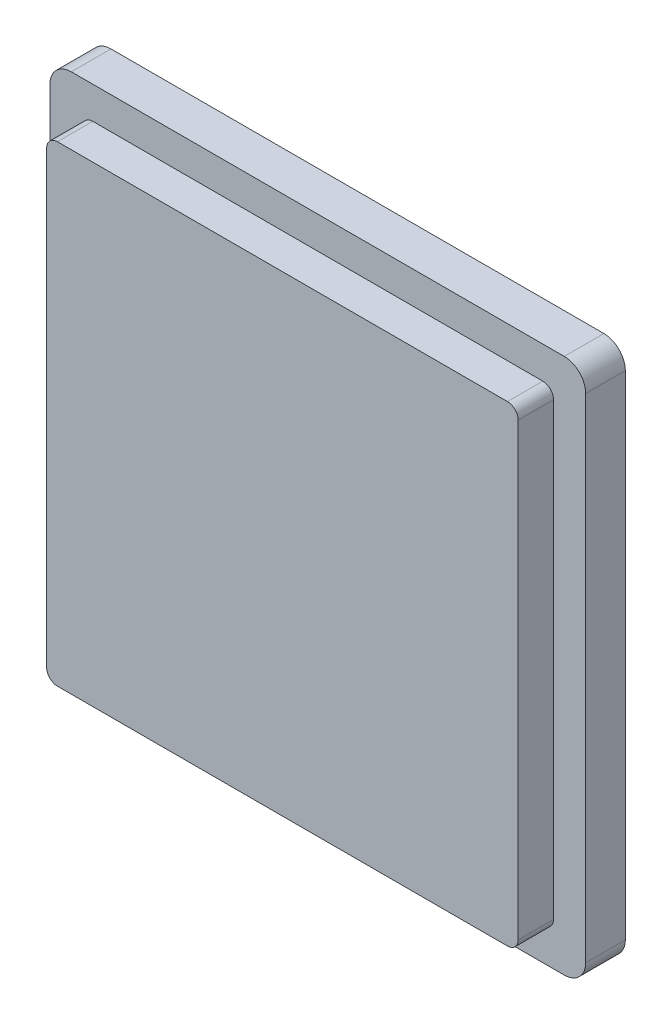
from build123d import *

# Parameters (mm, degrees)
RESSALTO_EXTRUS_O1_DEPTH = 3.7
RESSALTO_EXTRUS_O2_DEPTH = 3.3


with BuildPart() as part:
    # Esboço1 → Ressalto-extrusão1 (new body)
    with BuildSketch(Plane.XY):
        with BuildLine():
            Line((23, -25), (-23, -25))
            ThreePointArc((-23, -25), (-24.414213563, -24.414213562), (-25, -23))
            Line((-25, -23), (-25, 23))
            ThreePointArc((-25, 23), (-24.414213563, 24.414213562), (-23, 25))
            Line((-23, 25), (23, 25))
            ThreePointArc((23, 25), (24.414213563, 24.414213562), (25, 23))
            Line((25, 23), (25, -23))
            ThreePointArc((25, -23), (24.414213563, -24.414213562), (23, -25))
        make_face()
    extrude(amount=RESSALTO_EXTRUS_O1_DEPTH)

    # Esboço3 → Ressalto-extrusão2 (add)
    with BuildSketch(Plane.XY.offset(3.7)):
        with BuildLine():
            Line((-22, -21), (-22, 21))
            ThreePointArc((-22, 21), (-21.707106782, 21.707106781), (-21, 22))
            Line((-21, 22), (21, 22))
            ThreePointArc((21, 22), (21.707106782, 21.707106781), (22, 21))
            Line((22, 21), (22, -21))
            ThreePointArc((22, -21), (21.707106782, -21.707106781), (21, -22))
            Line((21, -22), (-21, -22))
            ThreePointArc((-21, -22), (-21.707106782, -21.707106781), (-22, -21))
        make_face()
    extrude(amount=RESSALTO_EXTRUS_O2_DEPTH)


solid = part.part
